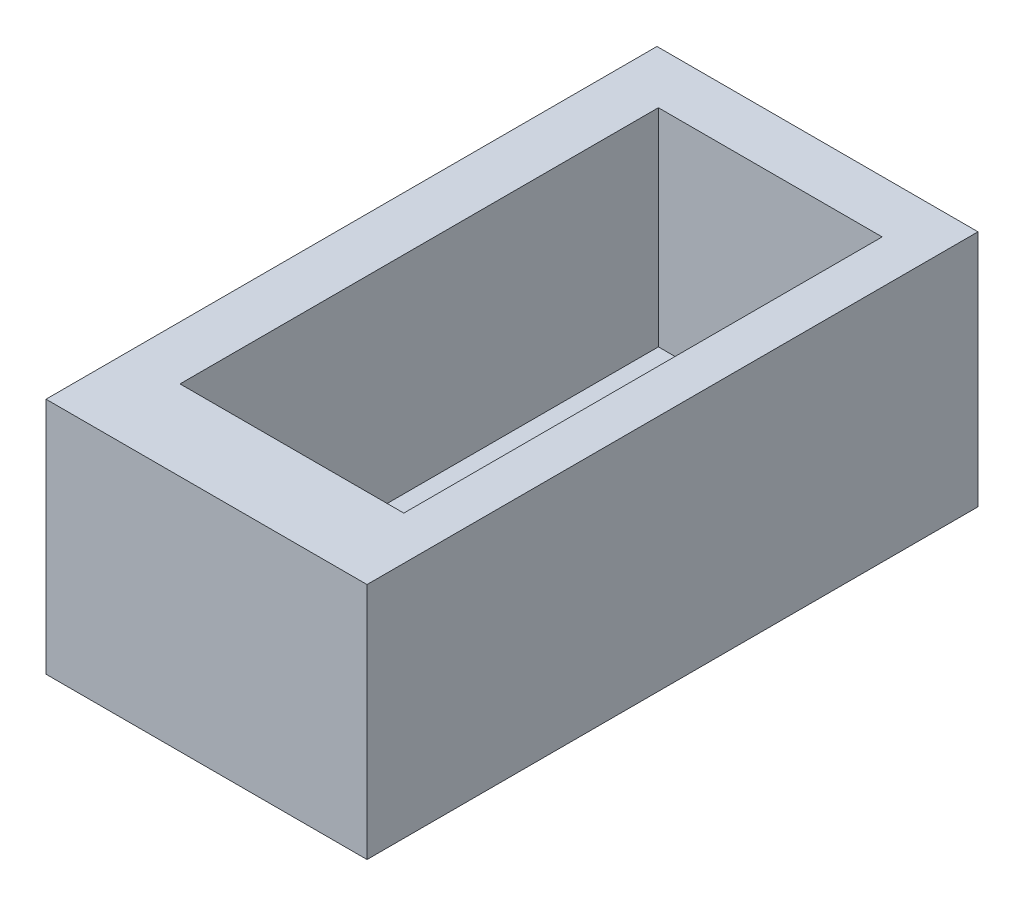
from build123d import *

# Parameters (mm, degrees)
SKETCH1_W           = 31
SKETCH1_H           = 59
BOSS_EXTRUDE1_DEPTH = 23
SKETCH2_W           = 21.609196656
SKETCH2_H           = 46.19436878
CUT_EXTRUDE1_DEPTH  = 20


with BuildPart() as part:
    # Sketch1 → Boss-Extrude1 (new body)
    with BuildSketch(Plane(origin=(0, 0, 0), x_dir=(1, 0, 0), z_dir=(0, 1, 0))):
        Rectangle(SKETCH1_W, SKETCH1_H)
    extrude(amount=BOSS_EXTRUDE1_DEPTH)

    # Sketch2 → Cut-Extrude1 (cut)
    with BuildSketch(Plane(origin=(0, 23, 0), x_dir=(1, 0, 0), z_dir=(0, 1, 0))):
        with Locations((0.497133186, 1.347240935)):
            Rectangle(SKETCH2_W, SKETCH2_H)
    extrude(amount=-CUT_EXTRUDE1_DEPTH, mode=Mode.SUBTRACT)


solid = part.part
